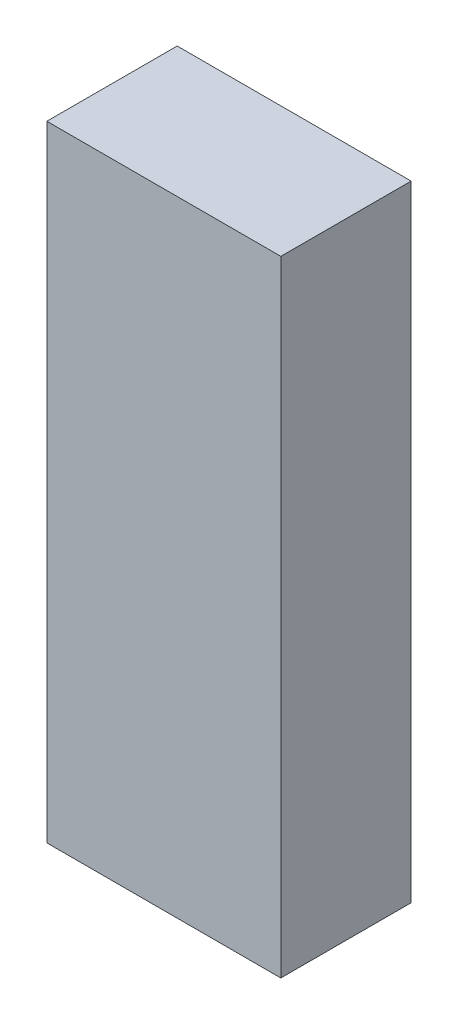
from build123d import *

# Parameters (mm, degrees)
SKETCH1_W           = 228
SKETCH1_H           = 609
BOSS_EXTRUDE1_DEPTH = 127


with BuildPart() as part:
    # Sketch1 → Boss-Extrude1 (new body)
    with BuildSketch(Plane.XY):
        Rectangle(SKETCH1_W, SKETCH1_H)
    extrude(amount=BOSS_EXTRUDE1_DEPTH)


solid = part.part
